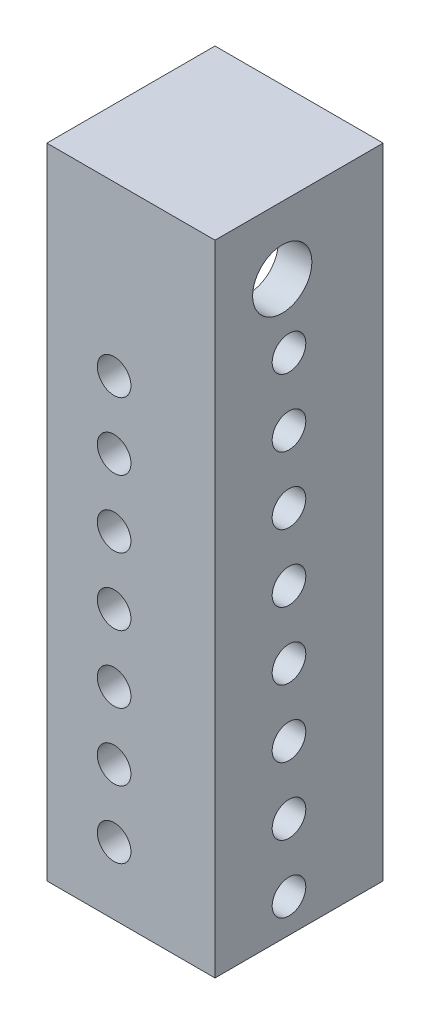
from build123d import *

# Parameters (mm, degrees)
SKETCH2_W           = 63.5
SKETCH2_H           = 63.5
BOSS_EXTRUDE1_DEPTH = 241.3
SKETCH4_W           = 50.8
SKETCH4_H           = 50.8
CUT_EXTRUDE1_DEPTH  = 95.25
SKETCH5_R           = 6.35
CUT_EXTRUDE2_DEPTH  = 64.5
SKETCH6_R           = 6.35
CUT_EXTRUDE3_DEPTH  = 12.7
CUT_EXTRUDE4_DEPTH  = 7.35
CUT_EXTRUDE6_START  = -31.75
CUT_EXTRUDE6_DEPTH  = 31.75
SKETCH37_W          = 8.89
SKETCH37_H          = 10.16
BOSS_EXTRUDE3_DEPTH = 10.16
SKETCH38_R          = 2.032
CUT_EXTRUDE8_DEPTH  = 58.674
FILLET4_R           = 3.81
SKETCH40_R          = 11.176
CUT_EXTRUDE10_DEPTH = 12.7


with BuildPart() as part:
    # Sketch2 → Boss-Extrude1 (new body)
    with BuildSketch(Plane(origin=(0, 0, 0), x_dir=(1, 0, 0), z_dir=(0, 1, 0))):
        with Locations((-9.601422319, 6.627899344)):
            Rectangle(SKETCH2_W, SKETCH2_H)
    extrude(amount=BOSS_EXTRUDE1_DEPTH)

    # Sketch4 → Cut-Extrude1 (cut, symmetric)
    with BuildSketch(Plane(origin=(0, 101.6, 0), x_dir=(1, 0, 0), z_dir=(0, 1, 0))):
        with Locations((-15.951422319, 12.977899344)):
            Rectangle(SKETCH4_W, SKETCH4_H)
    extrude(amount=CUT_EXTRUDE1_DEPTH, both=True, mode=Mode.SUBTRACT)

    # Sketch5 → Cut-Extrude2 (cut, through all)
    with BuildSketch(Plane.XY.offset(25.122100656)):
        with Locations((-15.951422319, 25.4)):
            Circle(SKETCH5_R)
        with Locations((-15.951422319, 50.8)):
            Circle(SKETCH5_R)
        with Locations((-15.951422319, 76.2)):
            Circle(SKETCH5_R)
        with Locations((-15.951422319, 101.6)):
            Circle(SKETCH5_R)
        with Locations((-15.951422319, 127)):
            Circle(SKETCH5_R)
        with Locations((-15.951422319, 152.4)):
            Circle(SKETCH5_R)
        with Locations((-15.951422319, 177.8)):
            Circle(SKETCH5_R)
    extrude(amount=-CUT_EXTRUDE2_DEPTH, mode=Mode.SUBTRACT)

    # Sketch6 → Cut-Extrude3 (cut)
    with BuildSketch(Plane(origin=(22.148577681, 0, 0), x_dir=(0, 0, -1), z_dir=(1, 0, 0))):
        with Locations((2.817899344, 12.7)):
            Circle(SKETCH6_R)
        with Locations((2.817899344, 38.1)):
            Circle(SKETCH6_R)
        with Locations((2.817899344, 63.5)):
            Circle(SKETCH6_R)
        with Locations((2.817899344, 88.9)):
            Circle(SKETCH6_R)
        with Locations((2.817899344, 114.3)):
            Circle(SKETCH6_R)
        with Locations((2.817899344, 139.7)):
            Circle(SKETCH6_R)
        with Locations((2.817899344, 165.1)):
            Circle(SKETCH6_R)
        with Locations((2.817899344, 190.5)):
            Circle(SKETCH6_R)
    extrude(amount=-CUT_EXTRUDE3_DEPTH, mode=Mode.SUBTRACT)

    # Sketch7 → Cut-Extrude4 (cut, through all)
    with BuildSketch(Plane(origin=(0, 6.35, 0), x_dir=(1, 0, 0), z_dir=(0, 1, 0))):
        Polygon((-41.351422319, 38.377899344), (9.448577681, 38.377899344), (9.448577681, 0.277899344), (9.448577681, -12.422100656), (-3.251422319, -12.422100656), (-41.351422319, -12.422100656), align=None)
    extrude(amount=-CUT_EXTRUDE4_DEPTH, mode=Mode.SUBTRACT)

    # Sketch34 → Cut-Extrude6 (cut)
    with BuildSketch(Plane.XZ.offset(-196.85).offset(CUT_EXTRUDE6_START)):
        Polygon((-3.251422319, 12.422100656), (9.448577681, 12.422100656), (9.448577681, -0.277899344), (9.448577681, -38.377899344), (-41.351422319, -38.377899344), (-41.351422319, 12.422100656), align=None)
    extrude(amount=CUT_EXTRUDE6_DEPTH, mode=Mode.SUBTRACT)

    # Sketch37 → Boss-Extrude3 (add)
    with BuildSketch(Plane(origin=(0, 228.6, 0), x_dir=(1, 0, 0), z_dir=(0, 1, 0))):
        with Locations((-32.080422319, 2.817899344)):
            Rectangle(SKETCH37_W, SKETCH37_H)
        with Locations((-15.316422319, 2.817899344)):
            Rectangle(SKETCH37_W, SKETCH37_H)
    extrude(amount=-BOSS_EXTRUDE3_DEPTH)

    # Sketch38 → Cut-Extrude8 (cut)
    with BuildSketch(Plane.ZY.offset(36.525422319)):
        with Locations((-2.817899344, 223.52)):
            Circle(SKETCH38_R)
    extrude(amount=-CUT_EXTRUDE8_DEPTH, mode=Mode.SUBTRACT)

    # Fillet4
    fillet4_edges = [part.edges().sort_by_distance(p)[0] for p in [
        (-32.080422319, 218.44, -7.897899344),
        (-32.080422319, 218.44, 2.262100656),
        (-15.316422319, 218.44, -7.897899344),
        (-15.316422319, 218.44, 2.262100656),
    ]]
    fillet(fillet4_edges, radius=FILLET4_R)

    # Sketch40 → Cut-Extrude10 (cut)
    with BuildSketch(Plane(origin=(22.148577681, 0, 0), x_dir=(0, 0, -1), z_dir=(1, 0, 0))):
        with Locations((0.277899344, 215.9)):
            Circle(SKETCH40_R)
    extrude(amount=-CUT_EXTRUDE10_DEPTH, mode=Mode.SUBTRACT)


solid = part.part
